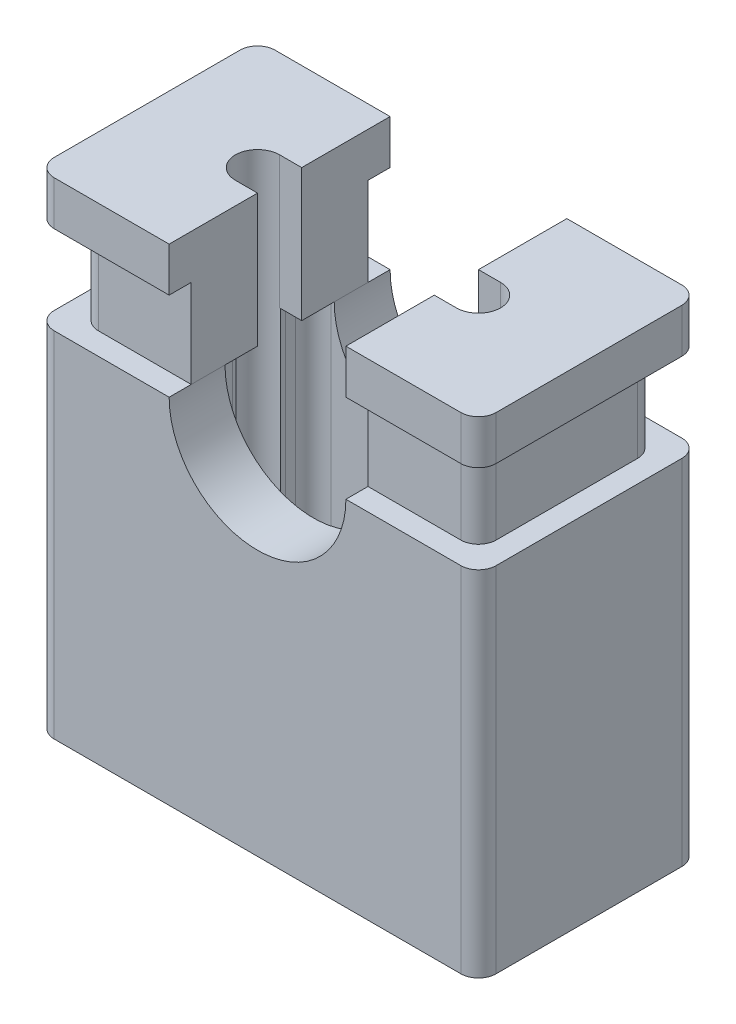
from build123d import *

# Parameters (mm, degrees)
Y_KSEKLIK_EKSTR_ZYON1_DEPTH = 4
Y_KSEKLIK_EKSTR_ZYON2_DEPTH = 1
Y_KSEKLIK_EKSTR_ZYON3_DEPTH = 0.5
KES_EKSTR_ZYON1_DEPTH       = 3.5


with BuildPart() as part:
    # Çizim1 → Yükseklik-Ekstrüzyon1 (new body)
    with BuildSketch(Plane(origin=(0, 0, 0), x_dir=(1, 0, 0), z_dir=(0, 1, 0))):
        with BuildLine():
            Line((-2.3, 1.25), (2.3, 1.25))
            ThreePointArc((2.3, 1.25), (2.441421356, 1.191421356), (2.5, 1.05))
            Line((2.5, 1.05), (2.5, -1.05))
            ThreePointArc((2.5, -1.05), (2.441421356, -1.191421356), (2.3, -1.25))
            Line((2.3, -1.25), (-2.3, -1.25))
            ThreePointArc((-2.3, -1.25), (-2.441421356, -1.191421356), (-2.5, -1.05))
            Line((-2.5, -1.05), (-2.5, 1.05))
            ThreePointArc((-2.5, 1.05), (-2.441421356, 1.191421356), (-2.3, 1.25))
        make_face()
        with BuildLine():
            Line((1.235851797, -0.3), (1.235851797, -0.417925898))
            ThreePointArc((1.235851797, -0.417925898), (1.177273153, -0.559347255), (1.035851797, -0.617925898))
            Line((1.035851797, -0.617925898), (-1.035851797, -0.617925898))
            ThreePointArc((-1.035851797, -0.617925898), (-1.177273153, -0.559347255), (-1.235851797, -0.417925898))
            Line((-1.235851797, -0.417925898), (-1.235851797, -0.3))
            ThreePointArc((-1.235851797, -0.3), (-1.237453719, -0.274737328), (-1.242233823, -0.249879344))
            ThreePointArc((-1.242233823, -0.249879344), (-1.5, 0), (-1.242233823, 0.249879344))
            ThreePointArc((-1.242233823, 0.249879344), (-1.237453719, 0.274737328), (-1.235851797, 0.3))
            Line((-1.235851797, 0.3), (-1.235851797, 0.417925898))
            ThreePointArc((-1.235851797, 0.417925898), (-1.177273153, 0.559347255), (-1.035851797, 0.617925898))
            Line((-1.035851797, 0.617925898), (1.035851797, 0.617925898))
            ThreePointArc((1.035851797, 0.617925898), (1.177273153, 0.559347255), (1.235851797, 0.417925898))
            Line((1.235851797, 0.417925898), (1.235851797, 0.3))
            ThreePointArc((1.235851797, 0.3), (1.237453719, 0.274737328), (1.242233823, 0.249879344))
            ThreePointArc((1.242233823, 0.249879344), (1.5, 0), (1.242233823, -0.249879344))
            ThreePointArc((1.242233823, -0.249879344), (1.237453719, -0.274737328), (1.235851797, -0.3))
        make_face(mode=Mode.SUBTRACT)
    extrude(amount=Y_KSEKLIK_EKSTR_ZYON1_DEPTH)

    # Çizim3 → Yükseklik-Ekstrüzyon2 (add)
    with BuildSketch(Plane(origin=(0, 4, 0), x_dir=(1, 0, 0), z_dir=(0, 1, 0))):
        with BuildLine():
            Line((-2.05, -1), (2.05, -1))
            ThreePointArc((2.05, -1), (2.191421356, -0.941421356), (2.25, -0.8))
            Line((2.25, -0.8), (2.25, 0.8))
            ThreePointArc((2.25, 0.8), (2.191421356, 0.941421356), (2.05, 1))
            Line((2.05, 1), (-2.05, 1))
            ThreePointArc((-2.05, 1), (-2.191421356, 0.941421356), (-2.25, 0.8))
            Line((-2.25, 0.8), (-2.25, -0.8))
            ThreePointArc((-2.25, -0.8), (-2.191421356, -0.941421356), (-2.05, -1))
        make_face()
        with BuildLine():
            Line((-1.25, 0.25), (1.25, 0.25))
            ThreePointArc((1.25, 0.25), (1.5, 0), (1.25, -0.25))
            Line((1.25, -0.25), (-1.25, -0.25))
            ThreePointArc((-1.25, -0.25), (-1.5, 0), (-1.25, 0.25))
        make_face(mode=Mode.SUBTRACT)
    extrude(amount=Y_KSEKLIK_EKSTR_ZYON2_DEPTH)

    # Çizim4 → Yükseklik-Ekstrüzyon3 (add)
    with BuildSketch(Plane(origin=(0, 5, 0), x_dir=(1, 0, 0), z_dir=(0, 1, 0))):
        with BuildLine():
            Line((-2.3, 1.25), (2.3, 1.25))
            ThreePointArc((2.3, 1.25), (2.441421356, 1.191421356), (2.5, 1.05))
            Line((2.5, 1.05), (2.5, -1.05))
            ThreePointArc((2.5, -1.05), (2.441421356, -1.191421356), (2.3, -1.25))
            Line((2.3, -1.25), (-2.3, -1.25))
            ThreePointArc((-2.3, -1.25), (-2.441421356, -1.191421356), (-2.5, -1.05))
            Line((-2.5, -1.05), (-2.5, 1.05))
            ThreePointArc((-2.5, 1.05), (-2.441421356, 1.191421356), (-2.3, 1.25))
        make_face()
        with BuildLine():
            ThreePointArc((2.25, 0.8), (2.191421356, 0.941421356), (2.05, 1))
            Line((2.05, 1), (-2.05, 1))
            ThreePointArc((-2.05, 1), (-2.191421356, 0.941421356), (-2.25, 0.8))
            Line((-2.25, 0.8), (-2.25, -0.8))
            ThreePointArc((-2.25, -0.8), (-2.191421356, -0.941421356), (-2.05, -1))
            Line((-2.05, -1), (2.05, -1))
            ThreePointArc((2.05, -1), (2.191421356, -0.941421356), (2.25, -0.8))
            Line((2.25, -0.8), (2.25, 0.8))
        make_face(mode=Mode.SUBTRACT)
        with BuildLine():
            Line((2.25, -0.8), (2.25, 0.8))
            ThreePointArc((2.25, 0.8), (2.191421356, 0.941421356), (2.05, 1))
            Line((2.05, 1), (-2.05, 1))
            ThreePointArc((-2.05, 1), (-2.191421356, 0.941421356), (-2.25, 0.8))
            Line((-2.25, 0.8), (-2.25, -0.8))
            ThreePointArc((-2.25, -0.8), (-2.191421356, -0.941421356), (-2.05, -1))
            Line((-2.05, -1), (2.05, -1))
            ThreePointArc((2.05, -1), (2.191421356, -0.941421356), (2.25, -0.8))
        make_face()
        with BuildLine():
            Line((1.25, -0.25), (-1.25, -0.25))
            ThreePointArc((-1.25, -0.25), (-1.5, 0), (-1.25, 0.25))
            Line((-1.25, 0.25), (1.25, 0.25))
            ThreePointArc((1.25, 0.25), (1.5, 0), (1.25, -0.25))
        make_face(mode=Mode.SUBTRACT)
    extrude(amount=Y_KSEKLIK_EKSTR_ZYON3_DEPTH)

    # Çizim5 → Kes-Ekstrüzyon1 (cut, through all)
    with BuildSketch(Plane(origin=(0, 0, -1.25), x_dir=(-1, 0, 0), z_dir=(0, 0, -1))):
        with BuildLine():
            Line((-1, 4), (-1, 5.5))
            Line((-1, 5.5), (1, 5.5))
            Line((1, 5.5), (1, 4))
            ThreePointArc((1, 4), (0, 3), (-1, 4))
        make_face()
    extrude(amount=-KES_EKSTR_ZYON1_DEPTH, mode=Mode.SUBTRACT)


solid = part.part
